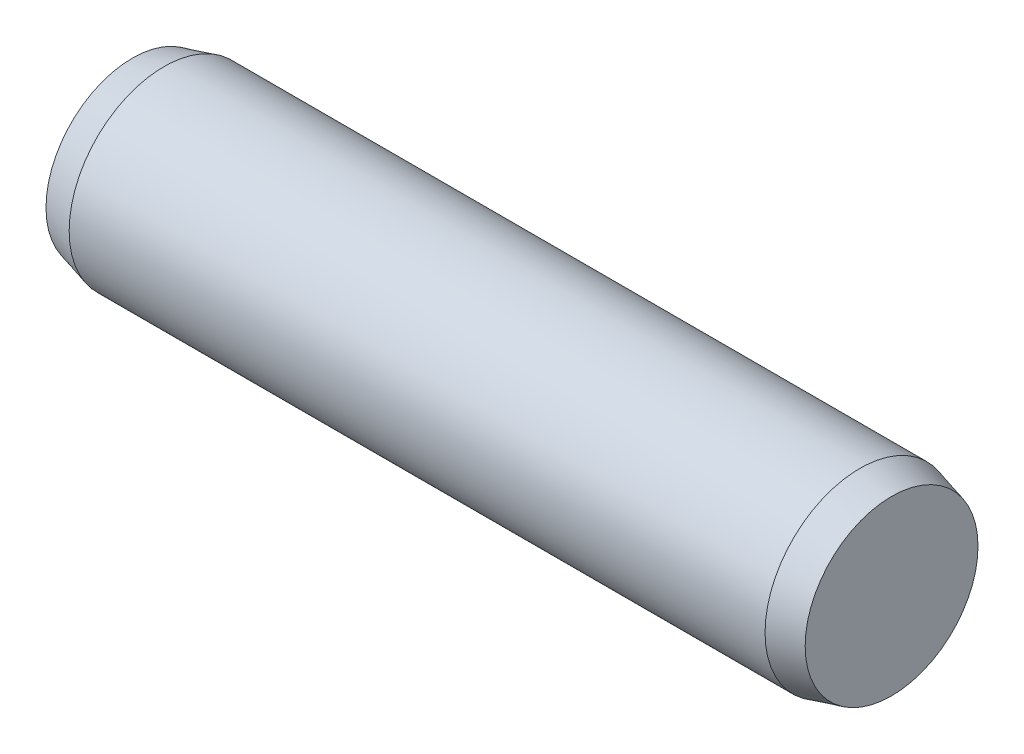
from build123d import *

# Parameters (mm, degrees)
SKETCH2_R           = 1.5
EXTRUDE1_DEPTH      = 5.5
EXTRUDE1_DEPTH_BACK = 5.5
SKETCH3_R           = 1.5
EXTRUDE2_DEPTH      = 0.5
EXTRUDE2_TAPER      = 15
SKETCH4_R           = 1.5
EXTRUDE3_DEPTH      = 0.5
EXTRUDE3_TAPER      = 15


with BuildPart() as part:
    # Sketch2 → Extrude1 (new body, two sides)
    with BuildSketch(Plane(origin=(0, 0, 0), x_dir=(0, 0, -1), z_dir=(1, 0, 0))) as extrude1_sk:
        Circle(SKETCH2_R)
    extrude(amount=EXTRUDE1_DEPTH)
    extrude(extrude1_sk.sketch, amount=-EXTRUDE1_DEPTH_BACK)

    # Sketch3 → Extrude2 (add)
    with BuildSketch(Plane(origin=(5.5, 0, 0), x_dir=(0, 0, -1), z_dir=(1, 0, 0))):
        Circle(SKETCH3_R)
    extrude(amount=EXTRUDE2_DEPTH, taper=EXTRUDE2_TAPER)

    # Sketch4 → Extrude3 (add)
    with BuildSketch(Plane.ZY.offset(5.5)):
        Circle(SKETCH4_R)
    extrude(amount=EXTRUDE3_DEPTH, taper=EXTRUDE3_TAPER)


solid = part.part
